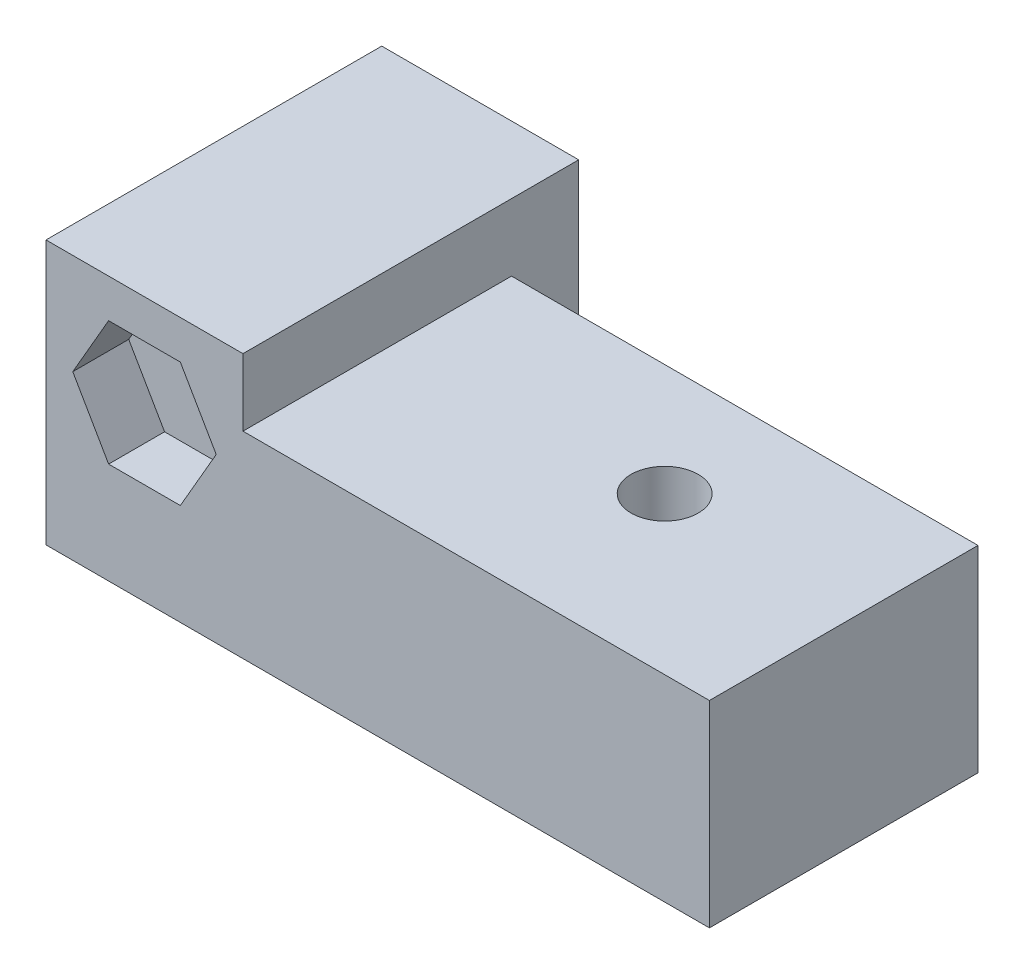
from build123d import *

# Parameters (mm, degrees)
SKETCH_1_W          = 4.8
SKETCH_1_H          = 7
EXTRUDE_1_DEPTH     = 15
SKETCH_2_W          = 5
SKETCH_2_H          = 7
EXTRUDE_2_DEPTH     = 5
SKETCH_3_R          = 1.5
CUT_EXTRUDE_1_DEPTH = 15
SKETCH_5_W          = 12
SKETCH_5_H          = 8.8
EXTRUDE_4_DEPTH     = 29.64
CUT_EXTRUDE_2_DEPTH = 2.5
CUT_EXTRUDE_3_REACH = 13
SKETCH_8_R          = 1.5
SKETCH_9_W          = 8.8
SKETCH_9_H          = 8.8
EXTRUDE_5_DEPTH     = 2
CUT_EXTRUDE_5_DEPTH = 2.5
SKETCH_11_R         = 1.5
CUT_EXTRUDE_7_DEPTH = 3.7
SKETCH_12_W         = 4.8
SKETCH_12_H         = 7
CUT_EXTRUDE_8_DEPTH = 10


with BuildPart() as part:
    # 草图1 → 凸台-拉伸1 (new body)
    with BuildSketch(Plane.XY):
        Polygon((-6.8, -0.219543147), (0, -0.219543147), (0, -11.219543147), (-6.8, -11.219543147), (-8.8, -11.219543147), (-8.8, -0.219543147), align=None)
        with Locations((-4.4, -4.719543147)):
            Rectangle(SKETCH_1_W, SKETCH_1_H, mode=Mode.SUBTRACT)
    extrude(amount=EXTRUDE_1_DEPTH)

    # 草图2 → 凸台-拉伸2 (add)
    with BuildSketch(Plane.ZY.offset(2)):
        with Locations((12.5, -4.719543147)):
            Rectangle(SKETCH_2_W, SKETCH_2_H)
    extrude(amount=EXTRUDE_2_DEPTH)

    # 草图3 → 切除-拉伸1 (cut)
    with BuildSketch(Plane.XY.offset(15)):
        with Locations((-4.4, -4.719543147)):
            Circle(SKETCH_3_R)
    extrude(amount=-CUT_EXTRUDE_1_DEPTH, mode=Mode.SUBTRACT)

    # 草图5 → 凸台-拉伸4 (add)
    with BuildSketch(Plane.ZY.offset(8.8)):
        with Locations((9, -7.619543147)):
            Rectangle(SKETCH_5_W, SKETCH_5_H)
    extrude(amount=-EXTRUDE_4_DEPTH)

    # 草图7 → 切除-拉伸2 (cut)
    with BuildSketch(Plane.XY.offset(15)):
        Polygon((-1.195706006, -4.719543147), (-2.797853003, -1.944543147), (-6.002146997, -1.944543147), (-7.604293994, -4.719543147), (-6.002146997, -7.494543147), (-2.797853003, -7.494543147), align=None)
    extrude(amount=-CUT_EXTRUDE_2_DEPTH, mode=Mode.SUBTRACT)

    # 草图8 → 切除-拉伸3 (cut, up to next)
    with BuildSketch(Plane(origin=(0, -11.219543147, 0), x_dir=(-1, 0, 0), z_dir=(0, 1, 0)), mode=Mode.PRIVATE) as cut_extrude_3_sk1:
        with Locations((4.4, 5)):
            Circle(SKETCH_8_R)
    cut_extrude_3_tool1 = extrude(cut_extrude_3_sk1.sketch, amount=CUT_EXTRUDE_3_REACH, mode=Mode.PRIVATE) & part.part
    add(cut_extrude_3_tool1.solids().sort_by_distance((-4.4, -11.219543, 5))[0], mode=Mode.SUBTRACT)

    # 草图9 → 凸台-拉伸5 (add)
    with BuildSketch(Plane(origin=(0, -11.219543147, 0), x_dir=(-1, 0, 0), z_dir=(0, 1, 0))):
        with Locations((4.4, 5)):
            Rectangle(SKETCH_9_W, SKETCH_9_H)
    extrude(amount=-EXTRUDE_5_DEPTH)

    # 草图10 → 切除-拉伸5 (cut)
    with BuildSketch(Plane.XZ.offset(13.219543147)):
        Polygon((-4.4, 1.795706006), (-1.625, 3.397853003), (-1.625, 6.602146997), (-4.4, 8.204293994), (-7.175, 6.602146997), (-7.175, 3.397853003), align=None)
    extrude(amount=-CUT_EXTRUDE_5_DEPTH, mode=Mode.SUBTRACT)

    # 草图11 → 切除-拉伸7 (cut)
    with BuildSketch(Plane(origin=(0, -3.219543147, 0), x_dir=(-1, 0, 0), z_dir=(0, 1, 0))):
        with Locations((-11.84, 8)):
            Circle(SKETCH_11_R)
    extrude(amount=-CUT_EXTRUDE_7_DEPTH, mode=Mode.SUBTRACT)

    # 草图12 → 切除-拉伸8 (cut)
    with BuildSketch(Plane(origin=(0, 0, 0), x_dir=(-1, 0, 0), z_dir=(0, 0, -1))):
        with Locations((4.4, -4.719543147)):
            Rectangle(SKETCH_12_W, SKETCH_12_H)
    extrude(amount=-CUT_EXTRUDE_8_DEPTH, mode=Mode.SUBTRACT)


solid = part.part
